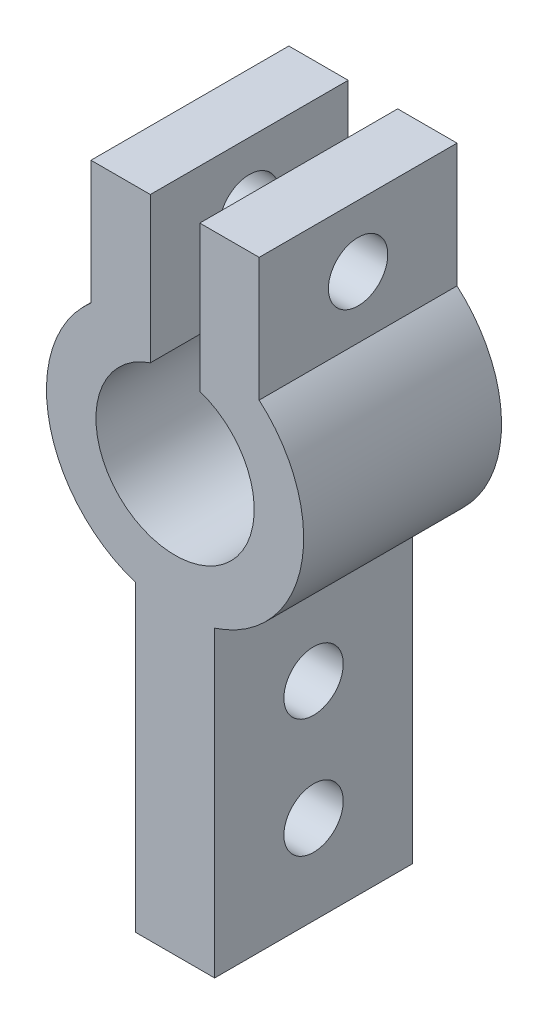
from build123d import *

# Parameters (mm, degrees)
BOSS_EXTRUDE1_DEPTH     = 10
SKETCH2_R               = 1.5
CUT_EXTRUDE1_DEPTH      = 3.25
CUT_EXTRUDE1_DEPTH_BACK = 11.75


with BuildPart() as part:
    # Sketch1 → Boss-Extrude1 (new body)
    with BuildSketch(Plane.XY):
        with BuildLine():
            ThreePointArc((2, -6.184658438), (0, -6.5), (-2, -6.184658438))
            Line((-2, -6.184658438), (-2, -21.5))
            Line((-2, -21.5), (2, -21.5))
            Line((2, -21.5), (2, -6.184658438))
        make_face()
        with BuildLine():
            Line((-2, -3.464101615), (-2, -6.184658438))
            ThreePointArc((-2, -6.184658438), (0, -6.5), (2, -6.184658438))
            Line((2, -6.184658438), (2, -3.464101615))
            ThreePointArc((2, -3.464101615), (0, -4), (-2, -3.464101615))
        make_face()
        with BuildLine():
            ThreePointArc((-1.25, 6.378675411), (-2.84531818, 5.844156436), (-4.25, 4.918078893))
            ThreePointArc((-4.25, 4.918078893), (-6.370503831, -1.290999975), (-2, -6.184658438))
            Line((-2, -6.184658438), (-2, -3.464101615))
            ThreePointArc((-2, -3.464101615), (-3.97884698, 0.410824427), (-1.25, 3.799671038))
            Line((-1.25, 3.799671038), (-1.25, 6.378675411))
        make_face()
        with BuildLine():
            ThreePointArc((4.25, 4.918078893), (2.84531818, 5.844156436), (1.25, 6.378675411))
            Line((1.25, 6.378675411), (1.25, 3.799671038))
            ThreePointArc((1.25, 3.799671038), (3.240370349, 2.34520788), (4, 0))
            ThreePointArc((4, 0), (3.464101615, -2), (2, -3.464101615))
            Line((2, -3.464101615), (2, -6.184658438))
            ThreePointArc((2, -6.184658438), (5.25594901, -3.824264635), (6.5, 0))
            ThreePointArc((6.5, 0), (5.910795209, 2.704163457), (4.25, 4.918078893))
        make_face()
        with BuildLine():
            Line((1.25, 11.168078893), (1.25, 6.378675411))
            ThreePointArc((1.25, 6.378675411), (2.84531818, 5.844156436), (4.25, 4.918078893))
            Line((4.25, 4.918078893), (4.25, 11.168078893))
            Line((4.25, 11.168078893), (1.25, 11.168078893))
        make_face()
        with BuildLine():
            Line((-4.25, 11.168078893), (-4.25, 4.918078893))
            ThreePointArc((-4.25, 4.918078893), (-2.84531818, 5.844156436), (-1.25, 6.378675411))
            Line((-1.25, 6.378675411), (-1.25, 11.168078893))
            Line((-1.25, 11.168078893), (-4.25, 11.168078893))
        make_face()
    extrude(amount=BOSS_EXTRUDE1_DEPTH)

    # Sketch2 → Cut-Extrude1 (cut, two sides)
    with BuildSketch(Plane(origin=(4.25, 0, 0), x_dir=(0, 0, -1), z_dir=(1, 0, 0))) as cut_extrude1_sk:
        with Locations((-5, 8.043078893)):
            Circle(SKETCH2_R)
        with Locations((-5, -17)):
            Circle(SKETCH2_R)
        with Locations((-5, -11)):
            Circle(SKETCH2_R)
    extrude(amount=CUT_EXTRUDE1_DEPTH, mode=Mode.SUBTRACT)
    extrude(cut_extrude1_sk.sketch, amount=-CUT_EXTRUDE1_DEPTH_BACK, mode=Mode.SUBTRACT)


solid = part.part
